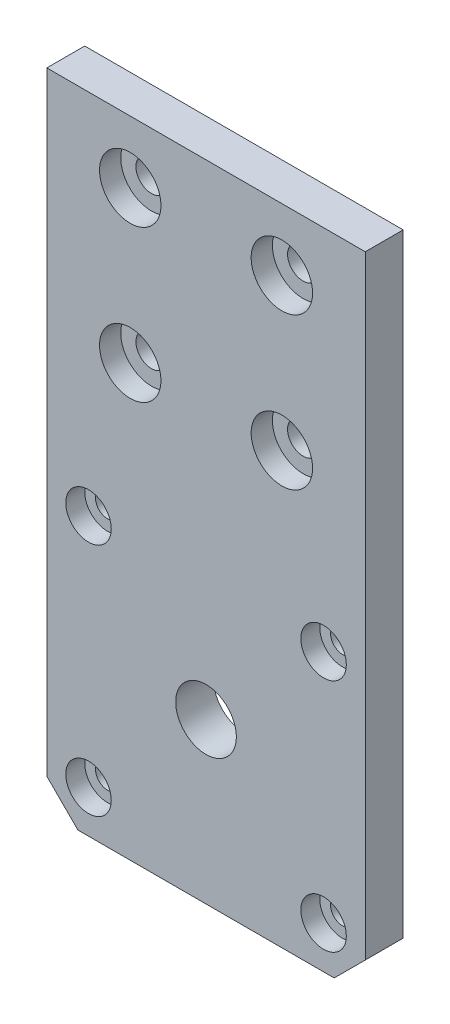
from build123d import *

# Parameters (mm, degrees)
CROQUIS1_W              = 42
CROQUIS1_H              = 85
CROQUIS1_R              = 2.05
SALIENTE_EXTRUIR1_DEPTH = 5
CROQUIS4_R              = 4.05
CORTAR_EXTRUIR1_DEPTH   = 2.8
CROQUIS5_R              = 1.575
CROQUIS5_R_2            = 4
CORTAR_EXTRUIR2_DEPTH   = 6
CROQUIS6_R              = 3
CORTAR_EXTRUIR3_DEPTH   = 2.5
CHAFL_N1_SIZE           = 4.1


with BuildPart() as part:
    # Croquis1 → Saliente-Extruir1 (new body)
    with BuildSketch(Plane.XY):
        with Locations((21, 42.5)):
            Rectangle(CROQUIS1_W, CROQUIS1_H)
        with Locations((11, 76.8)):
            Circle(CROQUIS1_R, mode=Mode.SUBTRACT)
        with Locations((31, 76.8)):
            Circle(CROQUIS1_R, mode=Mode.SUBTRACT)
        with Locations((31, 56.8)):
            Circle(CROQUIS1_R, mode=Mode.SUBTRACT)
        with Locations((11, 56.8)):
            Circle(CROQUIS1_R, mode=Mode.SUBTRACT)
    extrude(amount=SALIENTE_EXTRUIR1_DEPTH)

    # Croquis4 → Cortar-Extruir1 (cut)
    with BuildSketch(Plane.XY.offset(5)):
        with Locations((11, 76.8)):
            Circle(CROQUIS4_R)
        with Locations((11, 56.8)):
            Circle(CROQUIS4_R)
        with Locations((31, 56.8)):
            Circle(CROQUIS4_R)
        with Locations((31, 76.8)):
            Circle(CROQUIS4_R)
    extrude(amount=-CORTAR_EXTRUIR1_DEPTH, mode=Mode.SUBTRACT)

    # Croquis5 → Cortar-Extruir2 (cut, through all)
    with BuildSketch(Plane.XY.offset(5)):
        with Locations((5.5, 36.58)):
            Circle(CROQUIS5_R)
        with Locations((36.5, 36.58)):
            Circle(CROQUIS5_R)
        with Locations((36.5, 5.58)):
            Circle(CROQUIS5_R)
        with Locations((5.5, 5.58)):
            Circle(CROQUIS5_R)
        with Locations((21, 21.08)):
            Circle(CROQUIS5_R_2)
    extrude(amount=-CORTAR_EXTRUIR2_DEPTH, mode=Mode.SUBTRACT)

    # Croquis6 → Cortar-Extruir3 (cut)
    with BuildSketch(Plane.XY.offset(5)):
        with Locations((5.5, 36.58)):
            Circle(CROQUIS6_R)
        with Locations((36.5, 36.58)):
            Circle(CROQUIS6_R)
        with Locations((36.5, 5.58)):
            Circle(CROQUIS6_R)
        with Locations((5.5, 5.58)):
            Circle(CROQUIS6_R)
    extrude(amount=-CORTAR_EXTRUIR3_DEPTH, mode=Mode.SUBTRACT)

    # Chaflán1
    chafl_n1_edges = [part.edges().sort_by_distance(p)[0] for p in [
        (42, 0, 2.5),
        (0, 0, 2.5),
    ]]
    chamfer(chafl_n1_edges, length=CHAFL_N1_SIZE)


solid = part.part
